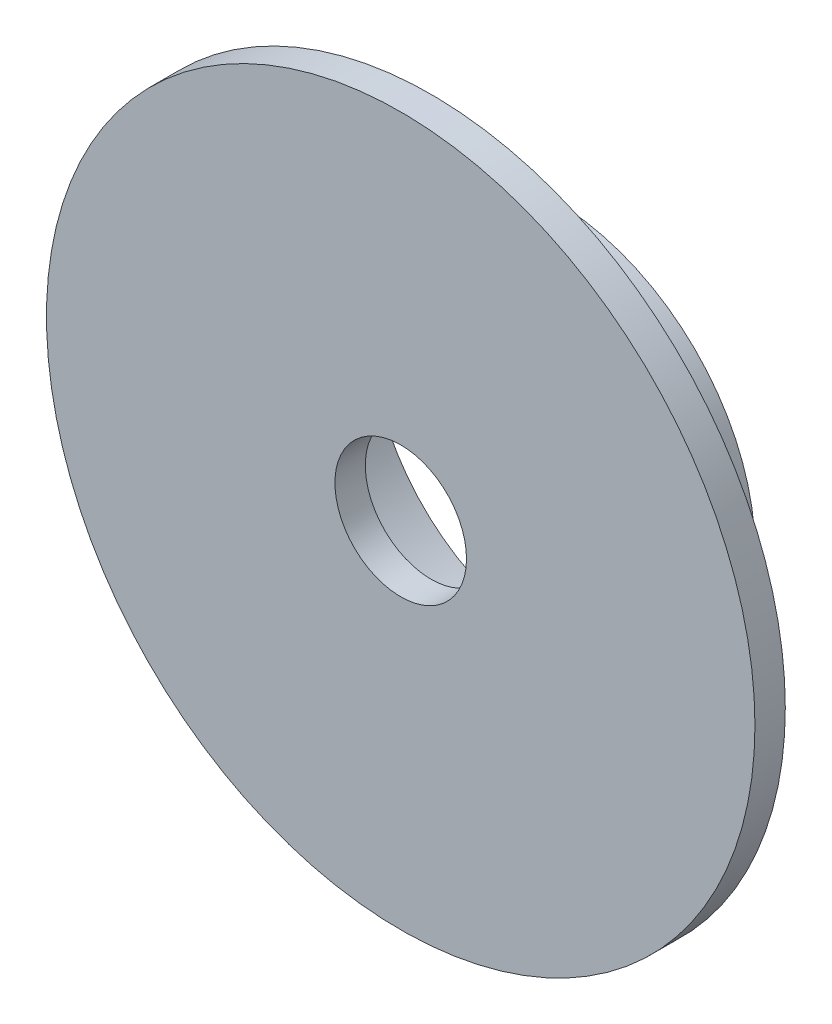
from build123d import *

# Parameters (mm, degrees)
SKETCH1_R           = 10
SKETCH1_R_2         = 3.25
BOSS_EXTRUDE1_DEPTH = 7.5
SKETCH2_R           = 9
CUT_EXTRUDE1_DEPTH  = 6
CUT_EXTRUDE2_DEPTH  = 6
CIRPATTERN1_COUNT   = 3
CIRPATTERN1_ANGLE   = 180
BOSS_EXTRUDE2_DEPTH = 6
CUT_EXTRUDE3_DEPTH  = 0.5
BOSS_EXTRUDE3_DEPTH = 3.5
BOSS_EXTRUDE4_DEPTH = 3
SKETCH8_R           = 17.5
SKETCH8_R_2         = 10
BOSS_EXTRUDE5_DEPTH = 1.5


with BuildPart() as part:
    # Sketch1 → Boss-Extrude1 (new body)
    with BuildSketch(Plane.XY):
        Circle(SKETCH1_R)
        Circle(SKETCH1_R_2, mode=Mode.SUBTRACT)
    extrude(amount=BOSS_EXTRUDE1_DEPTH)

    # Sketch2 → Cut-Extrude1 (cut)
    with BuildSketch(Plane.XY):
        Circle(SKETCH2_R)
    extrude(amount=CUT_EXTRUDE1_DEPTH, mode=Mode.SUBTRACT)

    # Sketch3 → Cut-Extrude2 (cut)
    with BuildSketch(Plane(origin=(0, 0, 0), x_dir=(-1, 0, 0), z_dir=(0, 0, -1))):
        with BuildLine():
            Line((0.75, -9.971835338), (0.75, -8.968695557))
            ThreePointArc((0.75, -8.968695557), (0, -9), (-0.75, -8.968695557))
            Line((-0.75, -8.968695557), (-0.75, -9.971835338))
            ThreePointArc((-0.75, -9.971835338), (0, -10), (0.75, -9.971835338))
        make_face()
    cut_extrude2 = extrude(amount=-CUT_EXTRUDE2_DEPTH, mode=Mode.SUBTRACT)

    # CirPattern1: Cut-Extrude2 ×3 about axis
    cirpattern1_axis = Axis((0, 0, 0), (0, 0, -1))
    for i in range(1, CIRPATTERN1_COUNT):
        add(cut_extrude2.rotate(cirpattern1_axis, i * CIRPATTERN1_ANGLE / (CIRPATTERN1_COUNT - 1)), mode=Mode.SUBTRACT)

    # Sketch4 → Boss-Extrude2 (add)
    with BuildSketch(Plane(origin=(0, 0, 6), x_dir=(-1, 0, 0), z_dir=(0, 0, -1))):
        with BuildLine():
            Line((-2.736161147, 7.517540966), (-2.394141003, 6.577848346))
            ThreePointArc((-2.394141003, 6.577848346), (-7, 0), (-2.394141003, -6.577848346))
            Line((-2.394141003, -6.577848346), (-2.736161147, -7.517540966))
            ThreePointArc((-2.736161147, -7.517540966), (-8, 0), (-2.736161147, 7.517540966))
        make_face()
    extrude(amount=BOSS_EXTRUDE2_DEPTH)

    # Sketch5 → Cut-Extrude3 (cut)
    with BuildSketch(Plane(origin=(0, 0, 6), x_dir=(-1, 0, 0), z_dir=(0, 0, -1))):
        with BuildLine():
            Line((-0.75, -8.968695557), (-0.75, -9.971835338))
            ThreePointArc((-0.75, -9.971835338), (0, -10), (0.75, -9.971835338))
            Line((0.75, -9.971835338), (0.75, -7.964766161))
            ThreePointArc((0.75, -7.964766161), (-8, 0), (0.75, 7.964766161))
            Line((0.75, 7.964766161), (0.75, 9.971835338))
            ThreePointArc((0.75, 9.971835338), (0, 10), (-0.75, 9.971835338))
            Line((-0.75, 9.971835338), (-0.75, 8.968695557))
            ThreePointArc((-0.75, 8.968695557), (-9, 0), (-0.75, -8.968695557))
        make_face()
    extrude(amount=-CUT_EXTRUDE3_DEPTH, mode=Mode.SUBTRACT)

    # Sketch6 → Boss-Extrude3 (add)
    with BuildSketch(Plane(origin=(0, 0, 6.5), x_dir=(-1, 0, 0), z_dir=(0, 0, -1))):
        with BuildLine():
            Line((-0.75, 8.968695557), (-0.75, 9.971835338))
            ThreePointArc((-0.75, 9.971835338), (-0.500156715, 9.987484331), (-0.25, 9.996874512))
            Line((-0.25, 9.996874512), (-0.25, 8.996527108))
            ThreePointArc((-0.25, 8.996527108), (-0.500193611, 8.986089603), (-0.75, 8.968695557))
        make_face()
    extrude(amount=BOSS_EXTRUDE3_DEPTH)

    # Sketch7 → Boss-Extrude4 (add)
    with BuildSketch(Plane(origin=(0, 0, 3), x_dir=(-1, 0, 0), z_dir=(0, 0, -1))):
        with BuildLine():
            ThreePointArc((0.25, 8.996527108), (0.500193611, 8.986089603), (0.75, 8.968695557))
            Line((0.75, 8.968695557), (0.75, 9.971835338))
            ThreePointArc((0.75, 9.971835338), (0.500156715, 9.987484331), (0.25, 9.996874512))
            Line((0.25, 9.996874512), (0.25, 8.996527108))
        make_face()
    extrude(amount=BOSS_EXTRUDE4_DEPTH)

    # Sketch8 → Boss-Extrude5 (add)
    with BuildSketch(Plane.XY.offset(7.5)):
        Circle(SKETCH8_R)
        Circle(SKETCH8_R_2, mode=Mode.SUBTRACT)
    extrude(amount=-BOSS_EXTRUDE5_DEPTH)


solid = part.part
